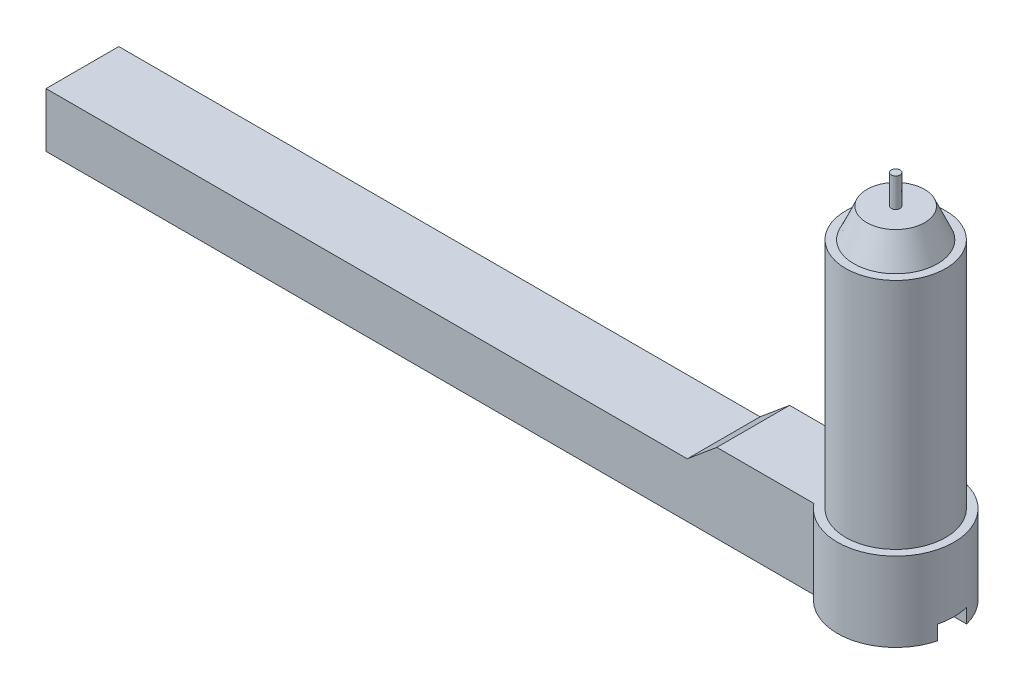
from build123d import *

# Parameters (mm, degrees)
BOSS_EXTRUDE1_DEPTH     = 9
CUT_EXTRUDE1_DEPTH      = 6
SKETCH3_R               = 3.434986687
BOSS_EXTRUDE2_DEPTH     = 16
SKETCH4_R               = 2.872742527
BOSS_EXTRUDE3_DEPTH     = 2
BOSS_EXTRUDE3_TAPER     = 24
SKETCH5_R               = 0.3
BOSS_EXTRUDE4_DEPTH     = 2
SKETCH6_W               = 59.861841092
SKETCH6_H               = 3.567823601
CUT_EXTRUDE2_DEPTH      = 2.5
CUT_EXTRUDE2_DEPTH_BACK = 7.5
SKETCH7_R               = 1
CUT_EXTRUDE3_DEPTH      = 3
SKETCH8_W               = 2
SKETCH8_H               = 1
CUT_EXTRUDE4_DEPTH      = 10.0001


with BuildPart() as part:
    # Sketch1 → Boss-Extrude1 (new body)
    with BuildSketch(Plane(origin=(0, 0, 0), x_dir=(1, 0, 0), z_dir=(0, 1, 0))):
        with BuildLine():
            Line((-42.647872244, 3.806239173), (10.091469849, 3.806239173))
            ThreePointArc((10.091469849, 3.806239173), (17.213968848, 1.306239173), (10.091469849, -1.193760827))
            Line((10.091469849, -1.193760827), (-42.647872244, -1.193760827))
            Line((-42.647872244, -1.193760827), (-42.647872244, 3.806239173))
        make_face()
    extrude(amount=BOSS_EXTRUDE1_DEPTH)

    # Sketch2 → Cut-Extrude1 (cut)
    with BuildSketch(Plane.XY.offset(1.193760827)):
        Polygon((1.39800972, 7.304936762), (3.426580057, 9), (1.39800972, 9), (-42.647872244, 9), (-42.647872244, 7.304936762), align=None)
    extrude(amount=-CUT_EXTRUDE1_DEPTH, mode=Mode.SUBTRACT)

    # Sketch3 → Boss-Extrude2 (add)
    with BuildSketch(Plane(origin=(0, 9, 0), x_dir=(1, 0, 0), z_dir=(0, 1, 0))):
        with Locations((13.213968848, 1.306239173)):
            Circle(SKETCH3_R)
    extrude(amount=BOSS_EXTRUDE2_DEPTH)

    # Sketch4 → Boss-Extrude3 (add)
    with BuildSketch(Plane(origin=(0, 25, 0), x_dir=(1, 0, 0), z_dir=(0, 1, 0))):
        with Locations((13.213968848, 1.306239173)):
            Circle(SKETCH4_R)
    extrude(amount=BOSS_EXTRUDE3_DEPTH, taper=BOSS_EXTRUDE3_TAPER)

    # Sketch5 → Boss-Extrude4 (add)
    with BuildSketch(Plane(origin=(0, 27, 0), x_dir=(1, 0, 0), z_dir=(0, 1, 0))):
        with Locations((13.213968848, 1.306239173)):
            Circle(SKETCH5_R)
    extrude(amount=BOSS_EXTRUDE4_DEPTH)

    # Sketch6 → Cut-Extrude2 (cut, two sides)
    with BuildSketch(Plane.XY.offset(1.193760827)) as cut_extrude2_sk:
        with Locations((-12.716951698, 1.783911801)):
            Rectangle(SKETCH6_W, SKETCH6_H)
    extrude(amount=CUT_EXTRUDE2_DEPTH, mode=Mode.SUBTRACT)
    extrude(cut_extrude2_sk.sketch, amount=-CUT_EXTRUDE2_DEPTH_BACK, mode=Mode.SUBTRACT)

    # Sketch7 → Cut-Extrude3 (cut)
    with BuildSketch(Plane.XZ.offset(-3.567823601)):
        with Locations((-39.22011329, -1.306239173)):
            Circle(SKETCH7_R)
    extrude(amount=-CUT_EXTRUDE3_DEPTH, mode=Mode.SUBTRACT)

    # Sketch8 → Cut-Extrude4 (cut)
    with BuildSketch(Plane(origin=(26, 0, 0), x_dir=(0, 0, -1), z_dir=(1, 0, 0))):
        with Locations((1.306239173, 4.067823601)):
            Rectangle(SKETCH8_W, SKETCH8_H)
    extrude(amount=-CUT_EXTRUDE4_DEPTH, mode=Mode.SUBTRACT)


solid = part.part
